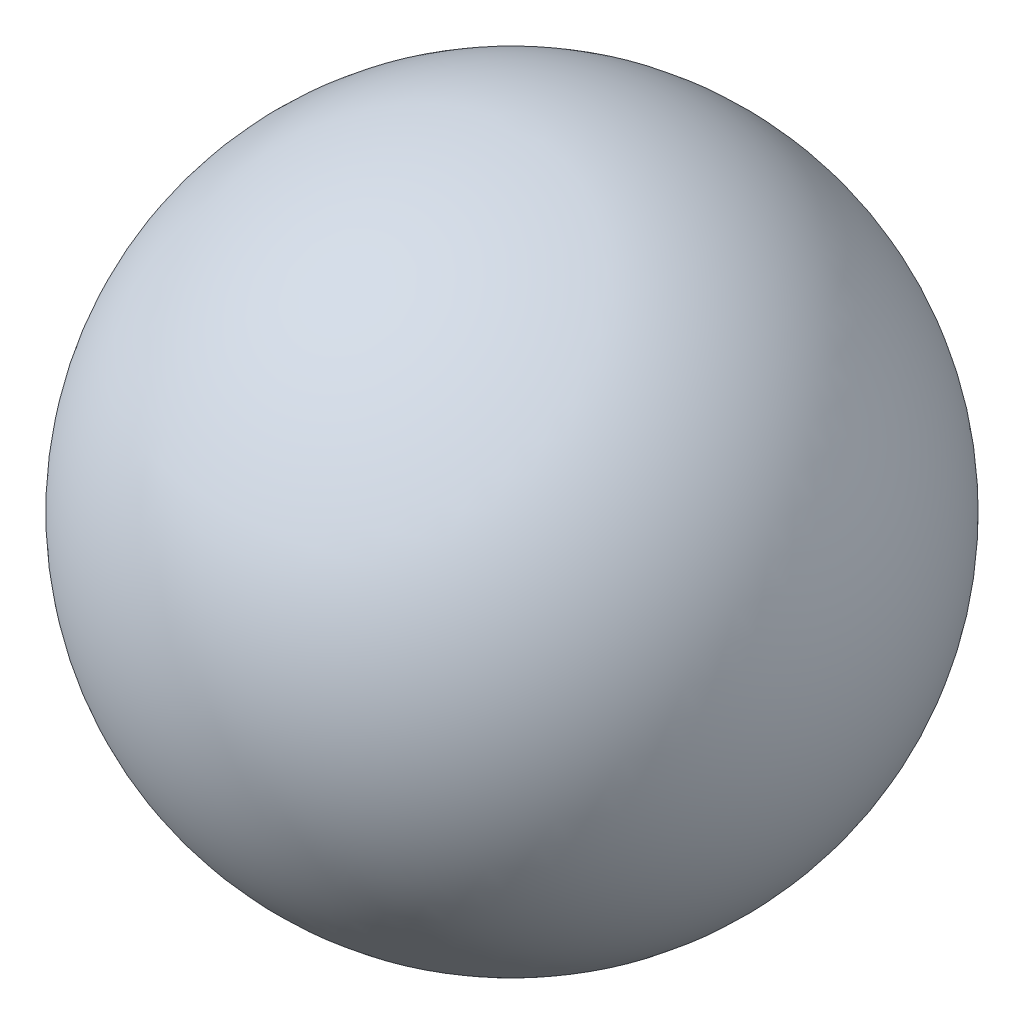
from build123d import *


with BuildPart() as part:
    # Sketch1 → Revolve1 (revolve)
    with BuildSketch(Plane.XY):
        with BuildLine():
            Line((0, 0), (0, 12.7))
            ThreePointArc((0, 12.7), (6.35, 6.35), (0, 0))
        make_face()
    revolve(axis=Axis((0, 0, 0), (0, 1, 0)))


solid = part.part
